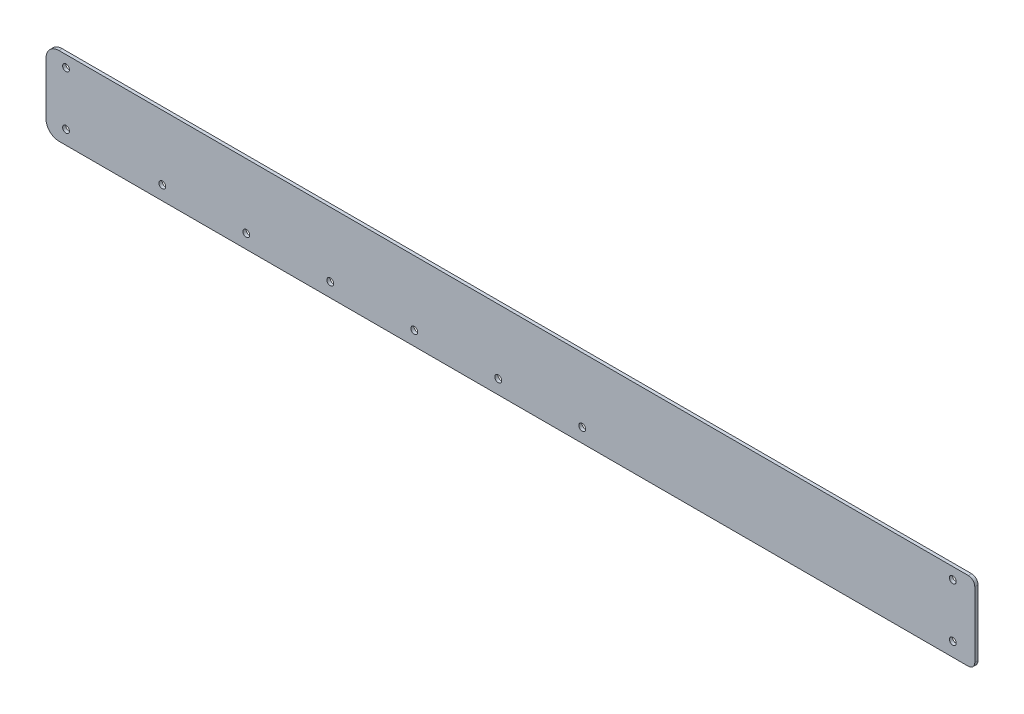
from build123d import *

# Parameters (mm, degrees)
MODEL_R            = 2.1
BOSS_EXTRU_1_DEPTH = 2


with BuildPart() as part:
    # Model → Boss.-Extru.1 (new body)
    with BuildSketch(Plane.XY):
        with BuildLine():
            Line((370.889379555, 211.968513878), (-192.127528462, 211.968513878))
            ThreePointArc((-192.127528462, 211.968513878), (-197.784382711, 209.625368128), (-200.127528462, 203.968513878))
            Line((-200.127528462, 203.968513878), (-200.127528462, 171.305548092))
            ThreePointArc((-200.127528462, 171.305548092), (-197.784382711, 165.648693842), (-192.127528462, 163.305548092))
            Line((-192.127528462, 163.305548092), (370.889379555, 163.305548092))
            ThreePointArc((370.889379555, 163.305548092), (373.71780668, 164.477120967), (374.889379555, 167.305548092))
            Line((374.889379555, 167.305548092), (374.889379555, 207.968513878))
            ThreePointArc((374.889379555, 207.968513878), (373.71780668, 210.796941003), (370.889379555, 211.968513878))
        make_face()
        with Locations((361.289379555, 204.922740721)):
            Circle(MODEL_R, mode=Mode.SUBTRACT)
        with Locations((-187.724187677, 204.922740721)):
            Circle(MODEL_R, mode=Mode.SUBTRACT)
        with Locations((-76.136887709, 171.922740721)):
            Circle(MODEL_R, mode=Mode.SUBTRACT)
        with Locations((-24.136887709, 171.922740721)):
            Circle(MODEL_R, mode=Mode.SUBTRACT)
        with Locations((-128.136887709, 171.922740721)):
            Circle(MODEL_R, mode=Mode.SUBTRACT)
        with Locations((131.863112291, 171.922740721)):
            Circle(MODEL_R, mode=Mode.SUBTRACT)
        with Locations((79.863112291, 171.922740721)):
            Circle(MODEL_R, mode=Mode.SUBTRACT)
        with Locations((27.863112291, 171.922740721)):
            Circle(MODEL_R, mode=Mode.SUBTRACT)
        with Locations((361.289379555, 171.922740721)):
            Circle(MODEL_R, mode=Mode.SUBTRACT)
        with Locations((-187.724187677, 171.922740721)):
            Circle(MODEL_R, mode=Mode.SUBTRACT)
    extrude(amount=BOSS_EXTRU_1_DEPTH)


solid = part.part
